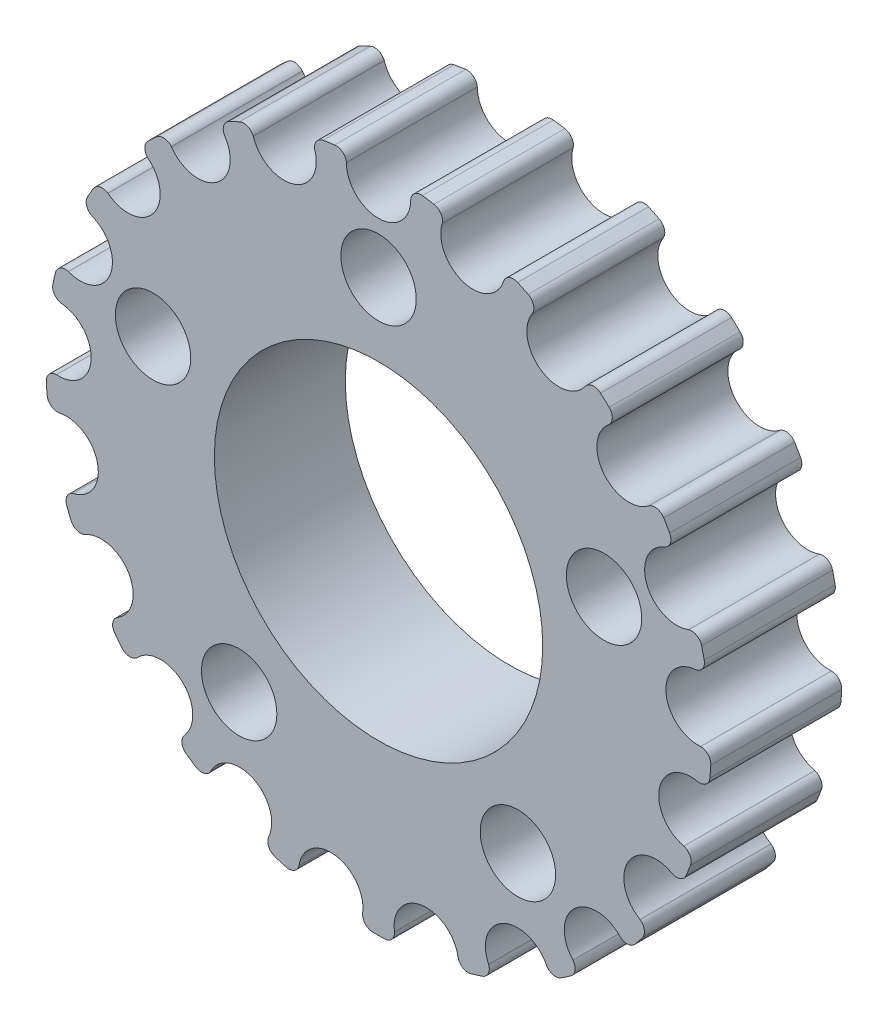
from build123d import *

# Parameters (mm, degrees)
SKETCH2_R                = 16.139769025
BOSS_EXTRUDE1_DEPTH      = 6.35
CUT_EXTRUDE1_DEPTH       = 7.35
FILLET1_R                = 0.5
CIRPATTERN1_COUNT        = 21
FILLET1_OF_CIRPATTERN1_R = 0.5
SKETCH4_R                = 7.9629
CUT_EXTRUDE2_DEPTH       = 7.35
F_6_CLEARANCE_HOLE1_D    = 3.6576
CIRPATTERN2_COUNT        = 5


with BuildPart() as part:
    # Sketch2 → Boss-Extrude1 (new body)
    with BuildSketch(Plane.XY):
        Circle(SKETCH2_R)
    extrude(amount=BOSS_EXTRUDE1_DEPTH)

    # Sketch3 → Cut-Extrude1 (cut, through all)
    with BuildSketch(Plane(origin=(0, 0, 0), x_dir=(-1, 0, 0), z_dir=(0, 0, -1))):
        with BuildLine():
            Line((-1.612129665, 16.059052964), (-1.56, 15.539769025))
            ThreePointArc((-1.56, 15.539769025), (0, 13.979769025), (1.56, 15.539769025))
            Line((1.56, 15.539769025), (1.612129665, 16.059052964))
            ThreePointArc((1.612129665, 16.059052964), (0, 16.139769025), (-1.612129665, 16.059052964))
        make_face()
    cut_extrude1 = extrude(amount=-CUT_EXTRUDE1_DEPTH, mode=Mode.SUBTRACT)

    # Fillet1
    fillet1_edges = [part.edges().sort_by_distance(p)[0] for p in [
        (1.612129665, 16.059052964, 3.175),
        (-1.612129665, 16.059052964, 3.175),
    ]]
    fillet(fillet1_edges, radius=FILLET1_R)

    # CirPattern1: Cut-Extrude1 ×21 about axis
    cirpattern1_axis = Axis((0, 0, 0), (0, 0, 1))
    for i in range(1, CIRPATTERN1_COUNT):
        add(cut_extrude1.rotate(cirpattern1_axis, i * 360 / CIRPATTERN1_COUNT), mode=Mode.SUBTRACT)

    # Fillet1 of CirPattern1
    fillet1_of_cirpattern1_edges = [part.edges().sort_by_distance(p)[0] for p in [
        (-3.192981691, 15.82077786, 3.175),
        (-6.273996224, 14.870410739, 3.175),
        (-7.71438261, 14.176757214, 3.175),
        (-10.378390686, 12.360467262, 3.175),
        (-11.550326781, 11.273069476, 3.175),
        (-13.560619591, 8.752242025, 3.175),
        (-14.35997373, 7.367720044, 3.175),
        (-15.537927936, 4.366341676, 3.175),
        (-15.893673995, 2.807716354, 3.175),
        (-16.134623196, -0.407527292, 3.175),
        (-16.015151577, -2.001765256, 3.175),
        (-15.29768638, -5.145185672, 3.175),
        (-14.71361266, -6.633381239, 3.175),
        (-13.101482996, -9.425671726, 3.175),
        (-12.104704689, -10.675592188, 3.175),
        (-9.741155353, -12.868645483, 3.175),
        (-8.420240586, -13.769229922, 3.175),
        (-5.515283308, -15.168183616, 3.175),
        (-3.987601155, -15.639411153, 3.175),
        (-0.799354138, -16.11996207, 3.175),
        (0.799354138, -16.11996207, 3.175),
        (3.987601155, -15.639411153, 3.175),
        (5.515283308, -15.168183616, 3.175),
        (8.420240586, -13.769229922, 3.175),
        (9.741155353, -12.868645483, 3.175),
        (12.104704689, -10.675592188, 3.175),
        (13.101482996, -9.425671726, 3.175),
        (14.71361266, -6.633381239, 3.175),
        (15.29768638, -5.145185672, 3.175),
        (16.015151577, -2.001765256, 3.175),
        (16.134623196, -0.407527292, 3.175),
        (15.893673995, 2.807716354, 3.175),
        (15.537927936, 4.366341676, 3.175),
        (14.35997373, 7.367720044, 3.175),
        (13.560619591, 8.752242025, 3.175),
        (11.550326781, 11.273069476, 3.175),
        (10.378390686, 12.360467262, 3.175),
        (7.71438261, 14.176757214, 3.175),
        (6.273996224, 14.870410739, 3.175),
        (3.192981691, 15.82077786, 3.175),
    ]]
    fillet(fillet1_of_cirpattern1_edges, radius=FILLET1_OF_CIRPATTERN1_R)

    # Sketch4 → Cut-Extrude2 (cut, through all)
    with BuildSketch(Plane.XY.offset(6.35)):
        Circle(SKETCH4_R)
    extrude(amount=-CUT_EXTRUDE2_DEPTH, mode=Mode.SUBTRACT)

    # #6 Clearance Hole1 (through all)
    with Locations(Plane.XY.offset(6.35)):
        with Locations((0, 11.5)):
            f_6_clearance_hole1 = Hole(F_6_CLEARANCE_HOLE1_D / 2)

    # CirPattern2: #6 Clearance Hole1 ×5 about axis
    cirpattern2_axis = Axis((0, 0, 0), (0, 0, 1))
    for i in range(1, CIRPATTERN2_COUNT):
        add(f_6_clearance_hole1.rotate(cirpattern2_axis, i * 360 / CIRPATTERN2_COUNT), mode=Mode.SUBTRACT)


solid = part.part
